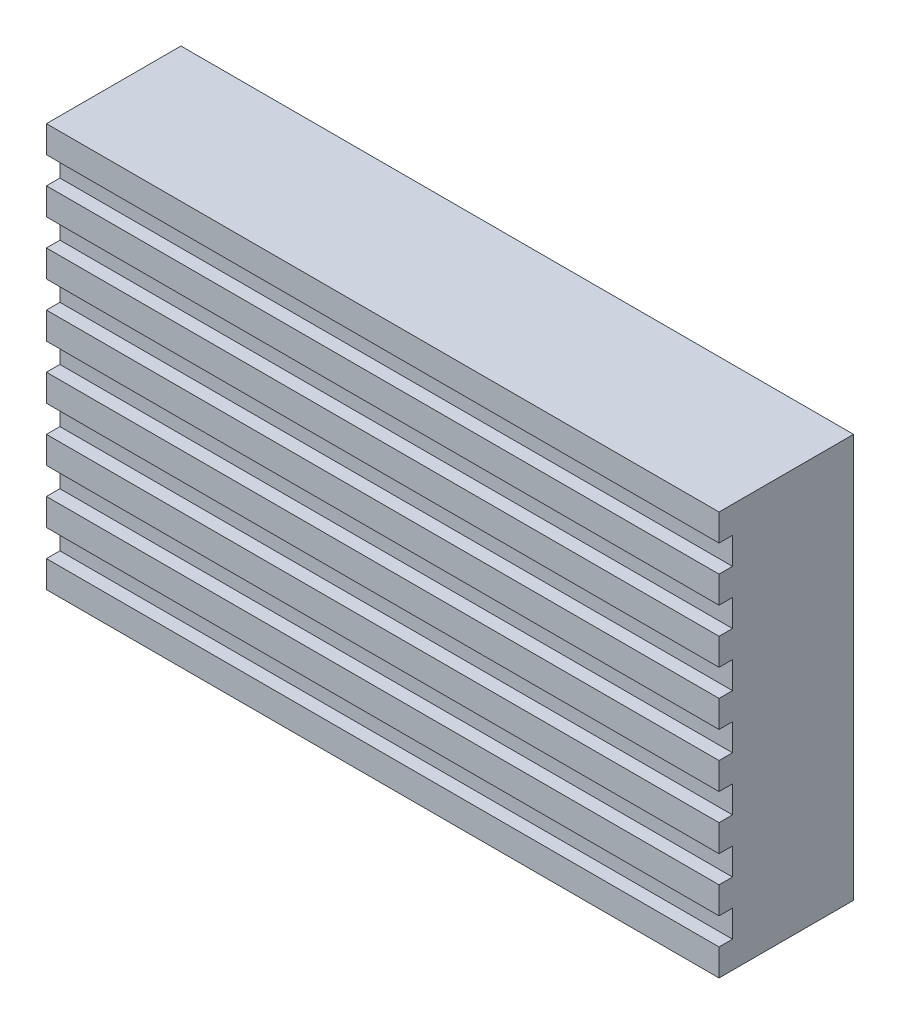
from build123d import *

# Parameters (mm, degrees)
SKETCH1_W           = 50
SKETCH1_H           = 30
BOSS_EXTRUDE1_DEPTH = 10
SKETCH2_W           = 50
SKETCH2_H           = 2
CUT_EXTRUDE3_DEPTH  = 1


with BuildPart() as part:
    # Sketch1 → Boss-Extrude1 (new body)
    with BuildSketch(Plane.XY):
        with Locations((-25, -15)):
            Rectangle(SKETCH1_W, SKETCH1_H)
    extrude(amount=BOSS_EXTRUDE1_DEPTH)

    # Sketch2 → Cut-Extrude3 (cut)
    with BuildSketch(Plane.XY.offset(10)):
        with Locations((-25, -3)):
            Rectangle(SKETCH2_W, SKETCH2_H)
        with Locations((-25, -7)):
            Rectangle(SKETCH2_W, SKETCH2_H)
        with Locations((-25, -11)):
            Rectangle(SKETCH2_W, SKETCH2_H)
        with Locations((-25, -15)):
            Rectangle(SKETCH2_W, SKETCH2_H)
        with Locations((-25, -19)):
            Rectangle(SKETCH2_W, SKETCH2_H)
        with Locations((-25, -23)):
            Rectangle(SKETCH2_W, SKETCH2_H)
        with Locations((-25, -27)):
            Rectangle(SKETCH2_W, SKETCH2_H)
    extrude(amount=-CUT_EXTRUDE3_DEPTH, mode=Mode.SUBTRACT)


solid = part.part
